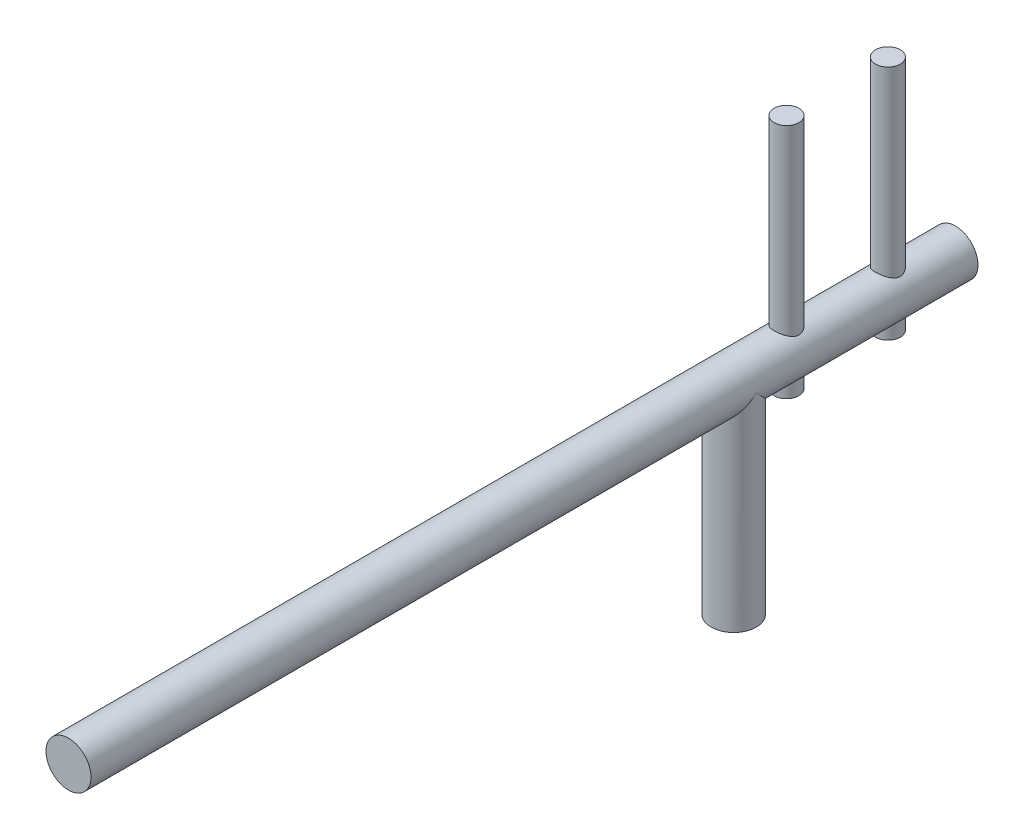
from build123d import *

# Parameters (mm, degrees)
SKETCH1_R                = 6.35
BOSS_EXTRUDE1_DEPTH      = 57.15
BOSS_EXTRUDE2_DEPTH      = 187.5
BOSS_EXTRUDE2_DEPTH_BACK = 62.5
SKETCH2_R                = 6.35
BOSS_EXTRUDE3_START      = 47.625
SKETCH3_R                = 3.5
BOSS_EXTRUDE3_DEPTH      = 66.675


with BuildPart() as part:
    # Sketch1 → Boss-Extrude1 (new body)
    with BuildSketch(Plane(origin=(0, 0, 0), x_dir=(1, 0, 0), z_dir=(0, 1, 0))):
        with Locations(Location((0, 0, 0), (0, 0, 270))):
            Circle(SKETCH1_R)
    extrude(amount=BOSS_EXTRUDE1_DEPTH)

    # Sketch2 → Boss-Extrude2 (add, two sides: drawn at the far end of the back side and taken through both)
    with BuildSketch(Plane.XY.offset(-BOSS_EXTRUDE2_DEPTH_BACK)):
        with Locations((0, 57.15)):
            Circle(SKETCH2_R)
    extrude(amount=BOSS_EXTRUDE2_DEPTH + BOSS_EXTRUDE2_DEPTH_BACK)

    # Sketch3 → Boss-Extrude3 (add)
    with BuildSketch(Plane(origin=(0, 0, 0), x_dir=(1, 0, 0), z_dir=(0, 1, 0)).offset(BOSS_EXTRUDE3_START)):
        with Locations(Location((0, 14.875, 0), (0, 0, 90))):
            Circle(SKETCH3_R)
        with Locations(Location((0, 43.45, 0), (0, 0, 90))):
            Circle(SKETCH3_R)
    extrude(amount=BOSS_EXTRUDE3_DEPTH)


solid = part.part
